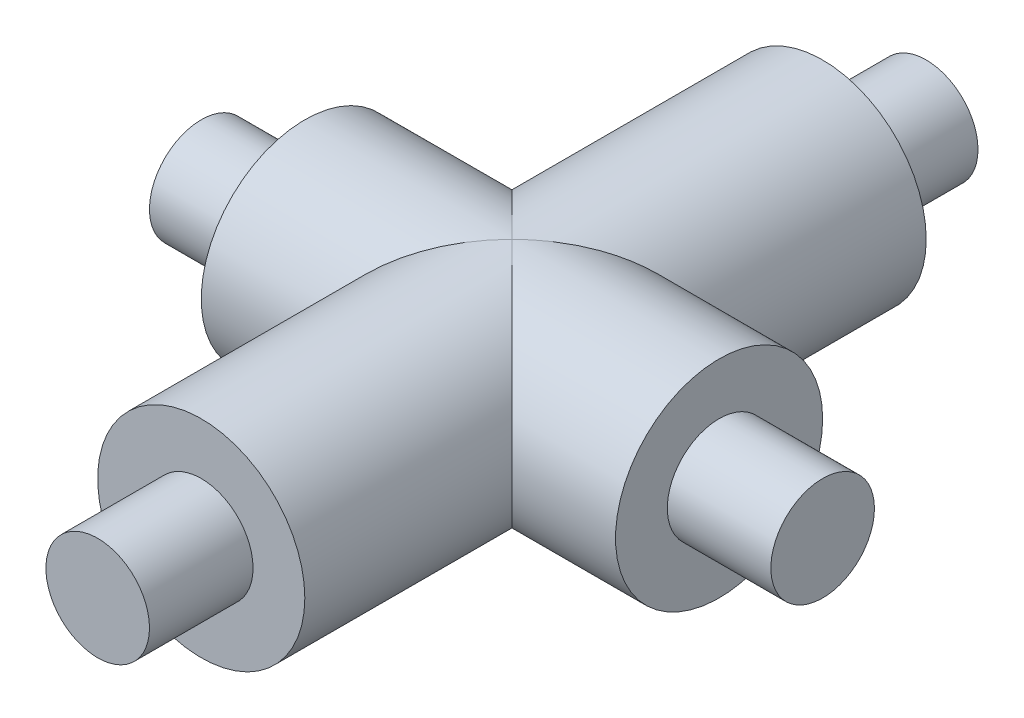
from build123d import *

# Parameters (mm, degrees)
SKETCH1_R                = 5
BOSS_EXTRUDE1_DEPTH      = 30
BOSS_EXTRUDE2_DEPTH      = 10
BOSS_EXTRUDE2_DEPTH_BACK = 10
SKETCH3_R                = 5
BOSS_EXTRUDE3_DEPTH      = 5
BOSS_EXTRUDE3_DEPTH_BACK = 25
SKETCH5_R                = 2.5
BOSS_EXTRUDE4_DEPTH      = 5
BOSS_EXTRUDE4_DEPTH_BACK = 35
SKETCH6_R                = 2.5


with BuildPart() as part:
    # Sketch1 → Boss-Extrude1 (new body)
    with BuildSketch(Plane.XY):
        Circle(SKETCH1_R)
    extrude(amount=-BOSS_EXTRUDE1_DEPTH)

    # Sketch3 → Boss-Extrude2 (add, two sides: drawn at the far end of the back side and taken through both)
    with BuildSketch(Plane(origin=(0, 0, 0), x_dir=(0, 0, -1), z_dir=(1, 0, 0)).offset(-BOSS_EXTRUDE2_DEPTH_BACK)):
        with Locations((15, 0)):
            Circle(SKETCH3_R)
    extrude(amount=BOSS_EXTRUDE2_DEPTH + BOSS_EXTRUDE2_DEPTH_BACK)

    # Sketch5 → Boss-Extrude3 (add, two sides: drawn at the far end of the back side and taken through both)
    with BuildSketch(Plane(origin=(10, 0, 0), x_dir=(0, 0, -1), z_dir=(1, 0, 0)).offset(-BOSS_EXTRUDE3_DEPTH_BACK)):
        with Locations((15, 0)):
            Circle(SKETCH5_R)
    extrude(amount=BOSS_EXTRUDE3_DEPTH + BOSS_EXTRUDE3_DEPTH_BACK)

    # Sketch6 → Boss-Extrude4 (add, two sides: drawn at the far end of the back side and taken through both)
    with BuildSketch(Plane.XY.offset(-BOSS_EXTRUDE4_DEPTH_BACK)):
        Circle(SKETCH6_R)
    extrude(amount=BOSS_EXTRUDE4_DEPTH + BOSS_EXTRUDE4_DEPTH_BACK)


solid = part.part
